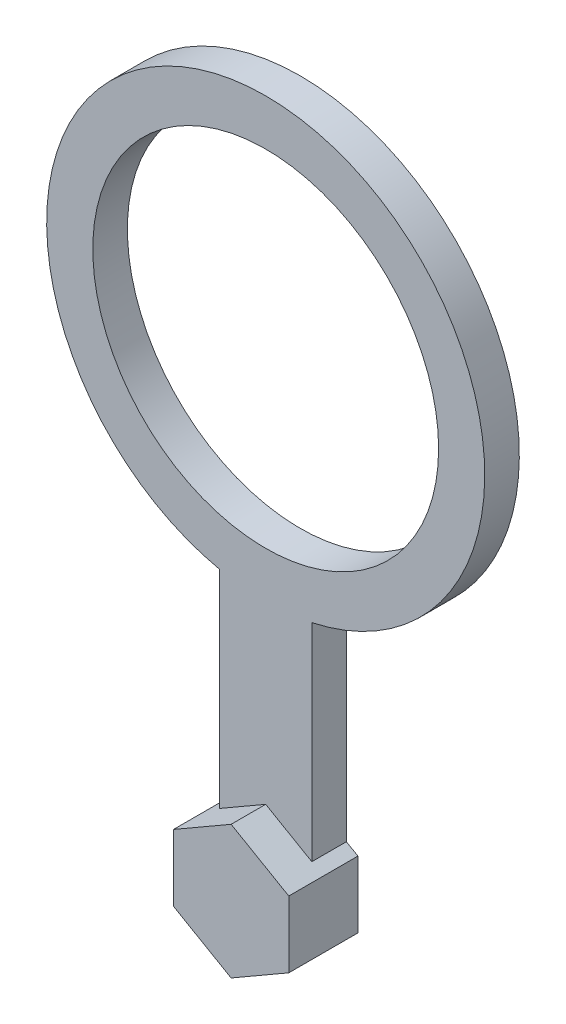
from build123d import *

# Parameters (mm, degrees)
SKETCH1_R           = 19
SKETCH1_R_2         = 15
BOSS_EXTRUDE1_DEPTH = 3
BOSS_EXTRUDE2_DEPTH = 3


with BuildPart() as part:
    # Sketch1 → Boss-Extrude1 (new body)
    with BuildSketch(Plane.XY):
        Polygon((5, -2.886751346), (5, 2.886751346), (0, 5.773502692), (-5, 2.886751346), (-5, -2.886751346), (0, -5.773502692), align=None)
        with BuildLine():
            Line((-4, 3.464101615), (0, 5.773502692))
            Line((0, 5.773502692), (4, 3.464101615))
            Line((4, 3.464101615), (4, 21.425824379))
            ThreePointArc((4, 21.425824379), (0, 21), (-4, 21.425824379))
            Line((-4, 21.425824379), (-4, 3.464101615))
        make_face()
        with Locations((0, 40)):
            Circle(SKETCH1_R)
        with Locations((0, 40)):
            Circle(SKETCH1_R_2, mode=Mode.SUBTRACT)
    extrude(amount=BOSS_EXTRUDE1_DEPTH)

    # Sketch2 → Boss-Extrude2 (add)
    with BuildSketch(Plane.XY.offset(3)):
        Polygon((0, -5.773502692), (5, -2.886751346), (5, 2.886751346), (0, 5.773502692), (-5, 2.886751346), (-5, -2.886751346), align=None)
    extrude(amount=BOSS_EXTRUDE2_DEPTH)


solid = part.part
